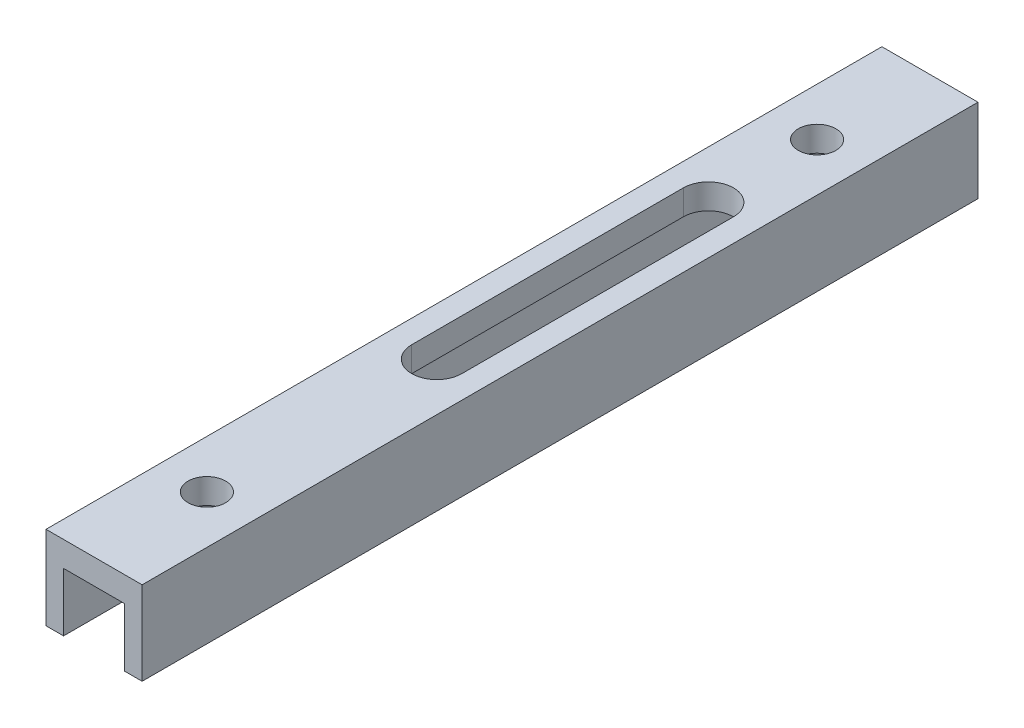
from build123d import *

# Parameters (mm, degrees)
BOSS_EXTRU_1_DEPTH      = 100
ESQUISSE2_R             = 2.25
ENL_V_MAT_EXTRU_1_DEPTH = 11


with BuildPart() as part:
    # Esquisse1 → Boss.-Extru.1 (new body)
    with BuildSketch(Plane.XY):
        Polygon((-5.75, 0), (5.75, 0), (5.75, -10), (3.65, -10), (3.65, -3), (-3.65, -3), (-3.65, -10), (-5.75, -10), align=None)
    extrude(amount=-BOSS_EXTRU_1_DEPTH)

    # Esquisse2 → Enlèv. mat.-Extru.1 (cut, through all)
    with BuildSketch(Plane(origin=(0, 0, 0), x_dir=(1, 0, 0), z_dir=(0, 1, 0))):
        with Locations(Location((0, 86.5, 0), (0, 0, 270))):  # turned: the seam where the file's is
            Circle(ESQUISSE2_R)
        with Locations(Location((0, 13.5, 0), (0, 0, 270))):  # turned: the seam where the file's is
            Circle(ESQUISSE2_R)
        with BuildLine():
            Line((-3, 73.5), (-3, 41))
            ThreePointArc((-3, 41), (0, 38), (3, 41))
            Line((3, 41), (3, 73.5))
            ThreePointArc((3, 73.5), (0, 76.5), (-3, 73.5))
        make_face()
    extrude(amount=-ENL_V_MAT_EXTRU_1_DEPTH, mode=Mode.SUBTRACT)


solid = part.part
